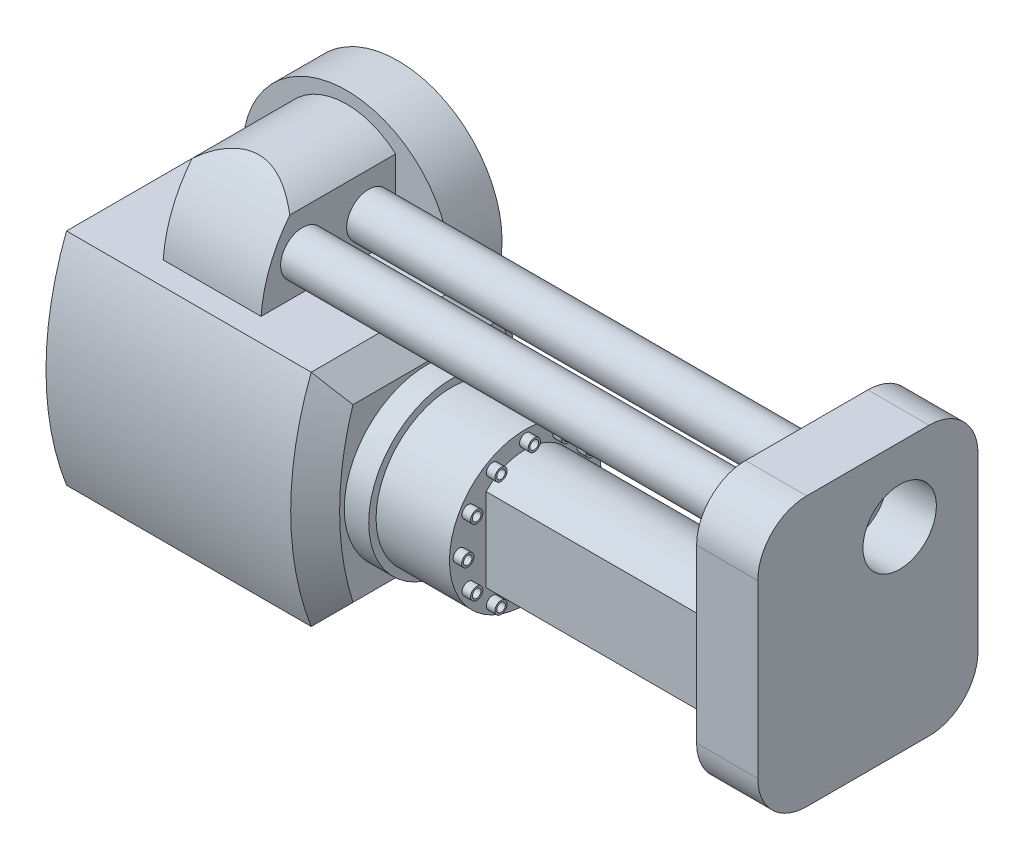
from build123d import *

# Parameters (mm, degrees)
BOSS_EXTRUDE1_DEPTH   = 100
BOSS_EXTRUDE2_DEPTH   = 10
BOSS_EXTRUDE2_DRAFT   = 45
SKETCH3_R             = 34
BOSS_EXTRUDE3_DEPTH   = 10
SKETCH4_R             = 31
BOSS_EXTRUDE4_DEPTH   = 30
SKETCH5_R             = 2.5
SKETCH5_R_2           = 1.75
BOSS_EXTRUDE5_DEPTH   = 3.5
CIRPATTERN1_COUNT     = 12
BOSS_EXTRUDE6_DEPTH   = 100
SKETCH10_R            = 42.5
BOSS_EXTRUDE10_DEPTH  = 10.5
BOSS_EXTRUDE11_DEPTH  = 30
BOSS_EXTRUDE12_DEPTH  = 40
CUT_EXTRUDE1_DEPTH    = 40
SKETCH14_R            = 15
BOSS_EXTRUDE13_DEPTH  = 25
SKETCH15_R            = 15
CUT_EXTRUDE2_DEPTH    = 20
SKETCH19_R            = 15
BOSS_EXTRUDE15_DEPTH  = 5
SKETCH16_R            = 9
BOSS_EXTRUDE16_DEPTH  = 180
BODY_MOVE_COPY2_ANGLE = 180
BODY_MOVE_COPY3_ANGLE = 180


with BuildPart() as part:
    # Sketch1 → Boss-Extrude1 (new body)
    with BuildSketch(Plane(origin=(0, 0, 0), x_dir=(0, 0, -1), z_dir=(1, 0, 0))):
        with BuildLine():
            Line((-37.5, 45), (37.5, 45))
            ThreePointArc((37.5, 45), (45.880962103, 0), (37.5, -45))
            Line((37.5, -45), (-37.5, -45))
            ThreePointArc((-37.5, -45), (-45.880962103, 0), (-37.5, 45))
        make_face()
    extrude(amount=BOSS_EXTRUDE1_DEPTH)


with BuildPart() as boss_extrude2_tool:
    # Sketch2 → Boss-Extrude2 (with draft: the straight prism first)
    with BuildSketch(Plane(origin=(100, 0, 0), x_dir=(0, 0, -1), z_dir=(1, 0, 0))):
        with BuildLine():
            Line((37.5, 45), (-37.5, 45))
            ThreePointArc((-37.5, 45), (-45.880962103, 0), (-37.5, -45))
            Line((-37.5, -45), (37.5, -45))
            ThreePointArc((37.5, -45), (45.880962103, 0), (37.5, 45))
        make_face()
    extrude(amount=BOSS_EXTRUDE2_DEPTH)
    # Boss-Extrude2: the draft: its side faces are tilted about the plane it starts from
    boss_extrude2_sides = [boss_extrude2_tool.faces().sort_by_distance(p)[0] for p in [
        (105, 45, 0),
        (105, 0, 45.880962103),
        (105, -45, 0),
        (105, 0, -45.880962103),
    ]]
    draft(boss_extrude2_sides, Plane(origin=(100, 0, 0), x_dir=(0, 0, -1), z_dir=(1, 0, 0)), BOSS_EXTRUDE2_DRAFT)


with BuildPart() as part_1:
    add(part.part)

    # Boss-Extrude2: add boss_extrude2_tool
    add(boss_extrude2_tool.part)

    # Sketch3 → Boss-Extrude3 (add)
    with BuildSketch(Plane(origin=(110, 0, 0), x_dir=(0, 0, -1), z_dir=(1, 0, 0))):
        Circle(SKETCH3_R)
    extrude(amount=BOSS_EXTRUDE3_DEPTH)

    # Sketch4 → Boss-Extrude4 (add)
    with BuildSketch(Plane(origin=(120, 0, 0), x_dir=(0, 0, -1), z_dir=(1, 0, 0))):
        Circle(SKETCH4_R)
    extrude(amount=BOSS_EXTRUDE4_DEPTH)

    # Sketch5 → Boss-Extrude5 (add)
    with BuildSketch(Plane(origin=(150, 0, 0), x_dir=(0, 0, -1), z_dir=(1, 0, 0))):
        with Locations((27, 0)):
            Circle(SKETCH5_R)
        with Locations((27, 0)):
            Circle(SKETCH5_R_2, mode=Mode.SUBTRACT)
    boss_extrude5 = extrude(amount=BOSS_EXTRUDE5_DEPTH)

    # CirPattern1: Boss-Extrude5 ×12 about axis
    cirpattern1_axis = Axis((0, 0, 0.17674784), (1, 0, 0))
    for i in range(1, CIRPATTERN1_COUNT):
        add(boss_extrude5.rotate(cirpattern1_axis, i * 360 / CIRPATTERN1_COUNT))

    # Sketch6 → Boss-Extrude6 (add)
    with BuildSketch(Plane(origin=(150, 0, 0), x_dir=(0, 0, -1), z_dir=(1, 0, 0))):
        with BuildLine():
            Line((16, 0), (16, 17))
            ThreePointArc((16, 17), (0, 23.900331129), (-16, 17))
            Line((-16, 17), (-16, 0))
            Line((-16, 0), (-16, -17))
            ThreePointArc((-16, -17), (0, -23.900331129), (16, -17))
            Line((16, -17), (16, 0))
        make_face()
    extrude(amount=BOSS_EXTRUDE6_DEPTH)

    # Sketch10 → Boss-Extrude10 (add, symmetric)
    with BuildSketch(Plane.XY.offset(37.5)):
        with Locations((50, -45)):
            Circle(SKETCH10_R)
    extrude(amount=BOSS_EXTRUDE10_DEPTH, both=True)

    # Sketch11 → Boss-Extrude11 (add)
    with BuildSketch(Plane(origin=(0, 0, 27), x_dir=(-1, 0, 0), z_dir=(0, 0, -1))):
        with BuildLine():
            Line((-50, -45), (-70, -45))
            Line((-70, -45), (-70, -75))
            ThreePointArc((-70, -75), (-50, -82.639320225), (-30, -75))
            Line((-30, -75), (-30, -45))
            Line((-30, -45), (-50, -45))
        make_face()
    extrude(amount=BOSS_EXTRUDE11_DEPTH)

    # Sketch12 → Boss-Extrude12 (add)
    with BuildSketch(Plane(origin=(70, 0, 0), x_dir=(0, 0, -1), z_dir=(1, 0, 0))):
        with BuildLine():
            Line((3, -45), (3, -87))
            ThreePointArc((3, -87), (20.421855105, -68.929675658), (28, -45))
            Line((28, -45), (3, -45))
        make_face()
    extrude(amount=-BOSS_EXTRUDE12_DEPTH)

    # Sketch13 → Cut-Extrude1 (cut)
    with BuildSketch(Plane.XY.offset(-3)):
        with BuildLine():
            Line((30, -75), (30, -87))
            Line((30, -87), (70, -87))
            Line((70, -87), (70, -75))
            ThreePointArc((70, -75), (50, -82.639320225), (30, -75))
        make_face()
    extrude(amount=-CUT_EXTRUDE1_DEPTH, mode=Mode.SUBTRACT)

    # Sketch14 → Boss-Extrude13 (add)
    with BuildSketch(Plane(origin=(250, 0, 0), x_dir=(0, 0, -1), z_dir=(1, 0, 0))):
        with BuildLine():
            Line((-40, 35), (10, 35))
            ThreePointArc((10, 35), (24.142135624, 29.142135624), (30, 15))
            Line((30, 15), (30, -55))
            ThreePointArc((30, -55), (24.142135624, -69.142135624), (10, -75))
            Line((10, -75), (-40, -75))
            ThreePointArc((-40, -75), (-54.142135624, -69.142135624), (-60, -55))
            Line((-60, -55), (-60, 15))
            ThreePointArc((-60, 15), (-54.142135624, 29.142135624), (-40, 35))
        make_face()
        with Locations((-28, -45)):
            Circle(SKETCH14_R, mode=Mode.SUBTRACT)
    extrude(amount=BOSS_EXTRUDE13_DEPTH)

    # Sketch15 → Cut-Extrude2 (cut)
    with BuildSketch(Plane.XY.offset(48)):
        with Locations((50, -45)):
            Circle(SKETCH15_R)
    extrude(amount=-CUT_EXTRUDE2_DEPTH, mode=Mode.SUBTRACT)

    # Sketch19 → Boss-Extrude15 (add)
    with BuildSketch(Plane.ZY.offset(-250)):
        with Locations((28, -45)):
            Circle(SKETCH19_R)
    extrude(amount=-BOSS_EXTRUDE15_DEPTH)

    # Sketch16 → Boss-Extrude16 (add)
    with BuildSketch(Plane(origin=(70, 0, 0), x_dir=(0, 0, -1), z_dir=(1, 0, 0))):
        with Locations((-16, -59)):
            Circle(SKETCH16_R)
        with Locations((11, -59)):
            Circle(SKETCH16_R)
    extrude(amount=BOSS_EXTRUDE16_DEPTH)


with BuildPart() as part_2:
    # Body-Move/Copy1: moved
    add(part_1.part.moved(Location((-50, 45, -28))))


with BuildPart() as part_3:
    # Body-Move/Copy2: moved
    add(part_2.part.rotate(Axis((0, 0, 0), (0, 1, 0)), BODY_MOVE_COPY2_ANGLE))


with BuildPart() as part_4:
    # Body-Move/Copy3: moved
    add(part_3.part.rotate(Axis((0, 0, 0), (0, 0, 1)), BODY_MOVE_COPY3_ANGLE))


solid = part_4.part
